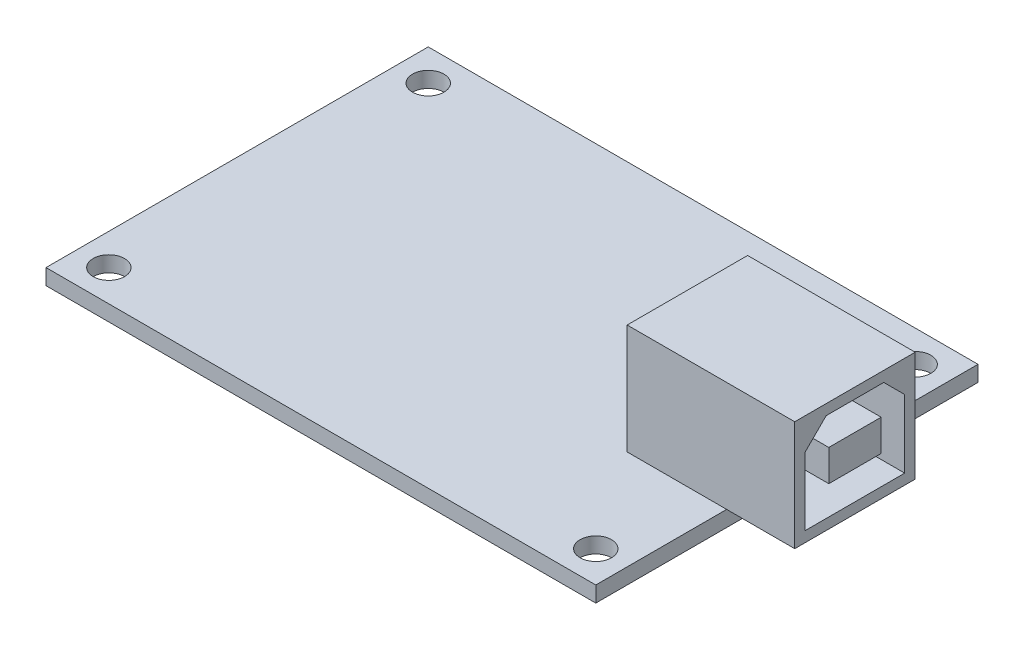
from build123d import *

# Parameters (mm, degrees)
SKETCH1_W           = 52.5
SKETCH1_H           = 36.5
SKETCH1_R           = 1.5
BOSS_EXTRUDE1_DEPTH = 1.5
SKETCH2_W           = 16
SKETCH2_H           = 11.5
BOSS_EXTRUDE2_DEPTH = 10.5
SKETCH7_W           = 5
SKETCH7_H           = 3
CUT_EXTRUDE1_DEPTH  = 10


with BuildPart() as part:
    # Sketch1 → Boss-Extrude1 (new body)
    with BuildSketch(Plane(origin=(0, 0, 0), x_dir=(1, 0, 0), z_dir=(0, 1, 0))):
        Rectangle(SKETCH1_W, SKETCH1_H)
        with Locations((-23.25, 15.25)):
            Circle(SKETCH1_R, mode=Mode.SUBTRACT)
        with Locations((23.25, 15.25)):
            Circle(SKETCH1_R, mode=Mode.SUBTRACT)
        with Locations((-23.25, -15.25)):
            Circle(SKETCH1_R, mode=Mode.SUBTRACT)
        with Locations((23.25, -15.25)):
            Circle(SKETCH1_R, mode=Mode.SUBTRACT)
    extrude(amount=BOSS_EXTRUDE1_DEPTH)

    # Sketch2 → Boss-Extrude2 (add)
    with BuildSketch(Plane(origin=(0, 1.5, 0), x_dir=(1, 0, 0), z_dir=(0, 1, 0))):
        with Locations((24.75, 0)):
            Rectangle(SKETCH2_W, SKETCH2_H)
    extrude(amount=BOSS_EXTRUDE2_DEPTH)

    # Sketch7 → Cut-Extrude1 (cut)
    with BuildSketch(Plane(origin=(32.75, 0, 0), x_dir=(0, 0, -1), z_dir=(1, 0, 0))):
        Polygon((-4.75, 2.5), (4.75, 2.5), (4.75, 9), (2.75, 11), (-2.75, 11), (-4.75, 9), align=None)
        with Locations((0, 6.75)):
            Rectangle(SKETCH7_W, SKETCH7_H, mode=Mode.SUBTRACT)
    extrude(amount=-CUT_EXTRUDE1_DEPTH, mode=Mode.SUBTRACT)


solid = part.part
